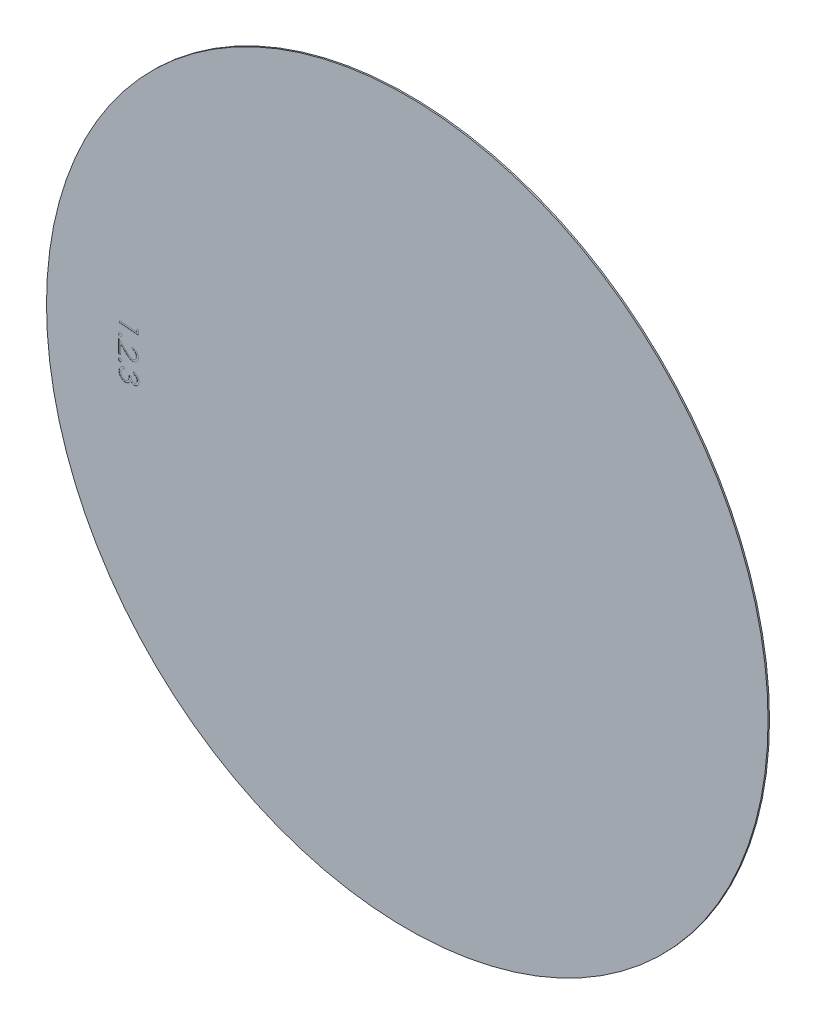
from build123d import *

# Parameters (mm, degrees)
ESQUISSE1_R             = 250
BOSS_EXTRU_1_DEPTH      = 1
ENL_V_MAT_EXTRU_1_DEPTH = 0.1


with BuildPart() as part:
    # Esquisse1 → Boss.-Extru.1 (new body)
    with BuildSketch(Plane.XY):
        Circle(ESQUISSE1_R)
    extrude(amount=BOSS_EXTRU_1_DEPTH)

    # Esquisse2 → Enl_v. mat.-Extru.1 (cut)
    with BuildSketch(Plane.XY.offset(1)):
        Polygon((-186.079389834, 15.769681634), (-186.275495269, 13.183209946), (-199.433109953, 14.171687343), (-199.332407162, 15.478173554), (-187.462728175, 14.585098801), (-187.309023915, 16.652156093), align=None)
        with BuildLine():
            add(Edge.make_bspline(
                [(-197.833748876, 7.192751147), (-197.838665779, 7.118953863), (-197.848276544, 6.974706863), (-197.914579868, 6.767389734), (-198.022946468, 6.580247834), (-198.165854608, 6.414154005), (-198.336130001, 6.275527541), (-198.531123371, 6.179387447), (-198.742825127, 6.120667213), (-198.889852697, 6.116374794), (-198.96533024, 6.114171253)],
                knots=[0, 0, 0, 0, 1.017333611, 1.988519244, 2.970953919, 3.982065248, 4.996402288, 5.977324361, 6.96164652, 8, 8, 8, 8], degree=3))
            add(Edge.make_bspline(
                [(-198.96533024, 6.114171253), (-199.039116519, 6.119100322), (-199.183342007, 6.12873487), (-199.390815461, 6.194865371), (-199.577940796, 6.304237384), (-199.74677394, 6.445156061), (-199.883980713, 6.616885694), (-199.983935465, 6.808389173), (-200.045762135, 7.016691776), (-200.049801761, 7.161405952), (-200.051860355, 7.235152323)],
                knots=[0, 0, 0, 0, 1.021012243, 1.995709639, 2.981696752, 4.005780596, 5.023785433, 6.002922688, 6.982289044, 8, 8, 8, 8], degree=3))
            add(Edge.make_bspline(
                [(-200.051860355, 7.235152323), (-200.0472576, 7.309060654), (-200.038243964, 7.453796324), (-199.967677802, 7.658625516), (-199.862605019, 7.847004622), (-199.716798437, 8.01131819), (-199.543891406, 8.148554803), (-199.350714607, 8.248655534), (-199.14096379, 8.306882188), (-198.996612072, 8.311417307), (-198.922929065, 8.313732217)],
                knots=[0, 0, 0, 0, 1.020640672, 1.998734222, 2.967693326, 3.990089689, 5.017298727, 6.006937189, 6.982659415, 8, 8, 8, 8], degree=3))
            add(Edge.make_bspline(
                [(-198.922929065, 8.313732217), (-198.84817015, 8.309026331), (-198.700928591, 8.299757843), (-198.49237845, 8.230087463), (-198.300819537, 8.125320541), (-198.136974108, 7.978812692), (-197.999836365, 7.809043454), (-197.897656985, 7.619358043), (-197.840795178, 7.410694724), (-197.836130115, 7.266403352), (-197.833748876, 7.192751147)],
                knots=[0, 0, 0, 0, 1.030886514, 2.030384459, 3.008194167, 4.02870078, 5.044454194, 6.010621071, 6.984539818, 8, 8, 8, 8], degree=3))
        make_face()
        with BuildLine():
            Line((-190.780872576, 2.713042324), (-190.780872576, 3.90027523))
            add(Edge.make_bspline(
                [(-190.780872576, 3.90027523), (-190.623365765, 3.892538796), (-190.314026581, 3.877344646), (-189.863021611, 3.806159559), (-189.431881867, 3.704396907), (-189.024303579, 3.560175489), (-188.635417883, 3.38207464), (-188.27038873, 3.164027661), (-187.925593251, 2.910682959), (-187.607559566, 2.622505307), (-187.316837015, 2.309805994), (-187.063126489, 1.974458577), (-186.851218479, 1.619909792), (-186.67310491, 1.249234844), (-186.539571382, 0.858146768), (-186.440448177, 0.450383928), (-186.380820524, 0.024103278), (-186.37441042, -0.266333383), (-186.371150353, -0.414044348)],
                knots=[0, 0, 0, 0, 1.100776268, 2.161895295, 3.184016182, 4.190939212, 5.176500551, 6.166955529, 7.155448256, 8.160289653, 9.16017456, 10.133824356, 11.091467644, 12.04088621, 13.000931625, 13.972173743, 14.968683325, 16, 16, 16, 16], degree=3))
            add(Edge.make_bspline(
                [(-186.371150353, -0.414044348), (-186.374546305, -0.55910433), (-186.381219228, -0.844142014), (-186.438524309, -1.260150223), (-186.528276992, -1.656183449), (-186.654201333, -2.031467567), (-186.823475806, -2.383008347), (-187.026817693, -2.71344664), (-187.261993841, -3.026716371), (-187.538875815, -3.30871225), (-187.834462208, -3.567656478), (-188.150026606, -3.79104893), (-188.475952775, -3.982354638), (-188.814726037, -4.141814023), (-189.169536174, -4.259198834), (-189.535217566, -4.348318846), (-189.915555393, -4.398693297), (-190.172981958, -4.406424511), (-190.303859355, -4.410355112)],
                knots=[0, 0, 0, 0, 1.111607364, 2.184268762, 3.212621178, 4.221274766, 5.211760367, 6.196651075, 7.1921475, 8.207485113, 9.220403448, 10.201281604, 11.166441695, 12.114753415, 13.065576456, 14.026450734, 14.996634279, 16, 16, 16, 16], degree=3))
            add(Edge.make_bspline(
                [(-190.303859355, -4.410355112), (-190.488114563, -4.403954981), (-190.853391561, -4.391267034), (-191.390173929, -4.282733527), (-191.910244293, -4.113224393), (-192.328804929, -3.90912724), (-192.666086289, -3.703234371), (-192.943780501, -3.51769528), (-193.242780337, -3.300491977), (-193.562084558, -3.04846313), (-193.904194229, -2.766822215), (-194.268902682, -2.453018204), (-194.652441812, -2.104813376), (-194.914400484, -1.860419638), (-195.050140905, -1.733780926)],
                knots=[0, 0, 0, 0, 1.184426356, 2.348067706, 3.509069118, 4.696110526, 5.333549288, 6.050745305, 6.844228056, 7.710549037, 8.667450064, 9.695053472, 10.805634456, 12, 12, 12, 12], degree=3))
            Line((-195.050140905, -1.733780926), (-198.582688815, 1.576160814))
            Line((-198.582688815, 1.576160814), (-198.582688815, -4.579959812))
            Line((-198.582688815, -4.579959812), (-199.939526422, -4.579959812))
            Line((-199.939526422, -4.579959812), (-199.939526422, 4.409089333))
            Line((-199.939526422, 4.409089333), (-194.464474672, -0.721452868))
            add(Edge.make_bspline(
                [(-194.464474672, -0.721452868), (-194.3340864, -0.846374855), (-194.083637212, -1.086324427), (-193.717878288, -1.425564838), (-193.378957107, -1.730747386), (-193.065371831, -2.002074512), (-192.778900194, -2.239769466), (-192.517297185, -2.443071728), (-192.282807805, -2.612879857), (-192.007339486, -2.792841089), (-191.670609832, -2.964446065), (-191.261178484, -3.11526928), (-190.838768951, -3.206575603), (-190.55340354, -3.21758459), (-190.409862293, -3.223122206)],
                knots=[0, 0, 0, 0, 1.329530082, 2.553755191, 3.672934919, 4.687409497, 5.60679272, 6.413407421, 7.126401618, 7.737995624, 8.834647426, 9.90044882, 10.943907757, 12, 12, 12, 12], degree=3))
            add(Edge.make_bspline(
                [(-190.409862293, -3.223122206), (-190.319586318, -3.220743934), (-190.141669707, -3.216056818), (-189.880987489, -3.173907196), (-189.628554084, -3.111981036), (-189.387490652, -3.016533694), (-189.15305594, -2.901857227), (-188.932377494, -2.755349583), (-188.717932917, -2.58792982), (-188.517075335, -2.393731106), (-188.333058601, -2.180537002), (-188.170063317, -1.955277612), (-188.033843148, -1.716965139), (-187.922176007, -1.466592737), (-187.834578517, -1.204861489), (-187.773880929, -0.931264349), (-187.735771535, -0.646557512), (-187.730615291, -0.452151143), (-187.72798796, -0.353092658)],
                knots=[0, 0, 0, 0, 0.991504627, 1.954065223, 2.895985987, 3.842598665, 4.797835564, 5.759220273, 6.74786863, 7.784730864, 8.824135544, 9.839918996, 10.835834653, 11.835434876, 12.84861661, 13.863796685, 14.911511676, 16, 16, 16, 16], degree=3))
            add(Edge.make_bspline(
                [(-187.72798796, -0.353092658), (-187.730689795, -0.249636968), (-187.735995751, -0.046467075), (-187.773134679, 0.251821565), (-187.837143711, 0.536407591), (-187.924898737, 0.807867088), (-188.035383012, 1.066461604), (-188.175651116, 1.309852927), (-188.340226467, 1.540263141), (-188.527833384, 1.757269063), (-188.737693955, 1.956663458), (-188.968753699, 2.135536432), (-189.222515633, 2.28809617), (-189.49324804, 2.423333512), (-189.788149357, 2.526810093), (-190.100073448, 2.615260879), (-190.433452007, 2.679513835), (-190.663142285, 2.701680536), (-190.780872576, 2.713042324)],
                knots=[0, 0, 0, 0, 1.031212865, 2.025131798, 2.990757446, 3.934781266, 4.865570067, 5.788494791, 6.729227313, 7.684356718, 8.643577152, 9.610526866, 10.590658432, 11.59095419, 12.621640561, 13.700587263, 14.82141059, 16, 16, 16, 16], degree=3))
        make_face()
        with BuildLine():
            add(Edge.make_bspline(
                [(-197.855890695, -7.952114521), (-197.856231935, -8.025785232), (-197.856903849, -8.170845472), (-197.913200599, -8.380783511), (-198.006935977, -8.576430894), (-198.143394723, -8.748287125), (-198.304408188, -8.898525716), (-198.495167443, -9.004694793), (-198.702469382, -9.077460631), (-198.849055583, -9.090361766), (-198.923870296, -9.096946252)],
                knots=[0, 0, 0, 0, 1.011455231, 1.991591199, 2.966042095, 3.981298704, 4.998232158, 5.979576679, 6.968815689, 8, 8, 8, 8], degree=3))
            add(Edge.make_bspline(
                [(-198.923870296, -9.096946252), (-198.997508424, -9.095459985), (-199.142458049, -9.09253441), (-199.352776447, -9.037452549), (-199.547473772, -8.942039331), (-199.723684047, -8.810838171), (-199.871461627, -8.647745362), (-199.98175034, -8.462057163), (-200.054719908, -8.257510728), (-200.067461559, -8.113494268), (-200.074002174, -8.039566945)],
                knots=[0, 0, 0, 0, 1.016752878, 2.001380979, 2.980297952, 4.002550597, 5.024144834, 6.005578797, 6.976212714, 8, 8, 8, 8], degree=3))
            add(Edge.make_bspline(
                [(-200.074002174, -8.039566945), (-200.072436201, -7.965961841), (-200.069353732, -7.821077221), (-200.015517685, -7.610674016), (-199.916130524, -7.418241398), (-199.781672277, -7.24563965), (-199.619277531, -7.09643759), (-199.432120375, -6.987000911), (-199.226129139, -6.917347401), (-199.082530999, -6.904165351), (-199.008672646, -6.897385288)],
                knots=[0, 0, 0, 0, 1.016913232, 2.00169662, 2.975252904, 3.995323461, 5.017078815, 6.009200989, 6.976051251, 8, 8, 8, 8], degree=3))
            add(Edge.make_bspline(
                [(-199.008672646, -6.897385288), (-198.933243948, -6.897687999), (-198.785579185, -6.898280608), (-198.572794984, -6.954153834), (-198.376389131, -7.04842455), (-198.205173897, -7.18469058), (-198.054984866, -7.343859595), (-197.944945481, -7.529266841), (-197.875936444, -7.734691858), (-197.862699165, -7.878267658), (-197.855890695, -7.952114521)],
                knots=[0, 0, 0, 0, 1.037885945, 2.031841802, 3.008281647, 4.025610493, 5.035601325, 6.014551791, 6.978803386, 8, 8, 8, 8], degree=3))
        make_face()
        with BuildLine():
            Line((-189.439623091, -11.988804985), (-189.542975956, -10.645217745))
            add(Edge.make_bspline(
                [(-189.542975956, -10.645217745), (-189.408296325, -10.667038857), (-189.144125712, -10.709840404), (-188.762207918, -10.807329372), (-188.400617113, -10.921814409), (-188.062889816, -11.063889185), (-187.745483079, -11.225051578), (-187.450084016, -11.411360412), (-187.176881613, -11.620710948), (-186.927088489, -11.851810389), (-186.702901019, -12.101603756), (-186.498943236, -12.363285339), (-186.327294074, -12.643427846), (-186.180335071, -12.935807444), (-186.061720893, -13.242475128), (-185.964915474, -13.560787287), (-185.898149365, -13.894634118), (-185.875957411, -14.122738594), (-185.864674006, -14.238717344)],
                knots=[0, 0, 0, 0, 1.169358419, 2.293666291, 3.376380236, 4.418758499, 5.431657949, 6.425660442, 7.408897509, 8.379064307, 9.339005395, 10.284371877, 11.219762931, 12.151312527, 13.086703581, 14.035674241, 15.001246929, 16, 16, 16, 16], degree=3))
            add(Edge.make_bspline(
                [(-185.864674006, -14.238717344), (-185.856682917, -14.408391366), (-185.840911864, -14.743256614), (-185.895219841, -15.242799697), (-186.005234102, -15.729258501), (-186.179001677, -16.195953942), (-186.397987529, -16.634703956), (-186.668627014, -17.030843658), (-186.982071521, -17.381889388), (-187.341166945, -17.676780771), (-187.725095529, -17.920013067), (-188.127771434, -18.105216632), (-188.543891818, -18.234826088), (-188.830147223, -18.268533449), (-188.973210164, -18.285379504)],
                knots=[0, 0, 0, 0, 1.079062385, 2.129615886, 3.184607817, 4.244094083, 5.289450633, 6.296237251, 7.286901598, 8.272517696, 9.242164218, 10.169895047, 11.085361559, 12, 12, 12, 12], degree=3))
            add(Edge.make_bspline(
                [(-188.973210164, -18.285379504), (-189.112011733, -18.291279474), (-189.384475039, -18.302860939), (-189.786011212, -18.249254941), (-190.170135959, -18.146085207), (-190.53498643, -17.985390623), (-190.881575024, -17.769812623), (-191.207532435, -17.498282401), (-191.521358495, -17.17751131), (-191.702287838, -16.92927749), (-191.795538389, -16.801338371)],
                knots=[0, 0, 0, 0, 0.993539459, 1.950288079, 2.888206921, 3.834604275, 4.795112071, 5.802201012, 6.867259652, 8, 8, 8, 8], degree=3))
            add(Edge.make_bspline(
                [(-191.795538389, -16.801338371), (-191.851865511, -16.959268109), (-191.962539105, -17.269574249), (-192.191553532, -17.703889484), (-192.469199712, -18.099377007), (-192.691645603, -18.329590144), (-192.8025663, -18.444383911)],
                knots=[0, 0, 0, 0, 1.032606511, 2.028903138, 3.017129792, 4, 4, 4, 4], degree=3))
            add(Edge.make_bspline(
                [(-192.8025663, -18.444383911), (-192.884185988, -18.52027061), (-193.044924382, -18.669718698), (-193.308091439, -18.862545711), (-193.578026931, -19.033836872), (-193.859664115, -19.176551879), (-194.150144903, -19.294816688), (-194.451381891, -19.383598617), (-194.761008565, -19.452828444), (-194.972645045, -19.473051739), (-195.078979395, -19.483212704)],
                knots=[0, 0, 0, 0, 1.046552868, 2.061037392, 3.060705633, 4.048305002, 5.024145354, 6.00379209, 6.997027972, 8, 8, 8, 8], degree=3))
            add(Edge.make_bspline(
                [(-195.078979395, -19.483212704), (-195.264630985, -19.490269303), (-195.633834425, -19.504302691), (-196.188049339, -19.430808784), (-196.732492497, -19.283681068), (-197.263100331, -19.066645898), (-197.765408033, -18.786552435), (-198.218893092, -18.439444235), (-198.61833056, -18.033731583), (-198.962542667, -17.574964304), (-199.247387278, -17.068284422), (-199.460290532, -16.519718), (-199.616887046, -15.938700302), (-199.660156733, -15.53553493), (-199.682156979, -15.330547606)],
                knots=[0, 0, 0, 0, 0.967291364, 1.923642562, 2.901252749, 3.901123817, 4.905482908, 5.891197214, 6.868286448, 7.865012392, 8.873387311, 9.888639405, 10.926489748, 12, 12, 12, 12], degree=3))
            add(Edge.make_bspline(
                [(-199.682156979, -15.330547606), (-199.68981465, -15.191889466), (-199.704886479, -14.918982506), (-199.686701635, -14.515857983), (-199.64426042, -14.127058269), (-199.563678417, -13.75462832), (-199.45185972, -13.397186966), (-199.30873098, -13.054400081), (-199.132848161, -12.727033093), (-198.925723242, -12.416056953), (-198.686528457, -12.123617215), (-198.41566643, -11.852941454), (-198.113749436, -11.606053908), (-197.784082303, -11.37907731), (-197.421063072, -11.178261089), (-197.028725666, -10.998305295), (-196.605117582, -10.841030843), (-196.309253065, -10.75713447), (-196.157559289, -10.714119655)],
                knots=[0, 0, 0, 0, 1.04323841, 2.053301916, 3.029289153, 3.979990115, 4.912429175, 5.841006599, 6.767873147, 7.701564391, 8.645283366, 9.603099554, 10.574853829, 11.573084318, 12.607558806, 13.689040711, 14.815139636, 16, 16, 16, 16], degree=3))
            Line((-196.157559289, -10.714119655), (-196.059506571, -12.002055352))
            add(Edge.make_bspline(
                [(-196.059506571, -12.002055352), (-196.160529318, -12.039198272), (-196.356270458, -12.111166199), (-196.63685521, -12.230103298), (-196.892684177, -12.360057958), (-197.127759191, -12.495329377), (-197.340471276, -12.637532003), (-197.528395306, -12.789144656), (-197.696732188, -12.945687958), (-197.791202281, -13.060981975), (-197.837705857, -13.117736275)],
                knots=[0, 0, 0, 0, 1.214465976, 2.353142868, 3.436371674, 4.450190844, 5.412268196, 6.319822283, 7.172920562, 8, 8, 8, 8], degree=3))
            add(Edge.make_bspline(
                [(-197.837705857, -13.117736275), (-197.890579497, -13.190883013), (-197.996077552, -13.336831705), (-198.1250981, -13.574909304), (-198.23253924, -13.823735821), (-198.310000786, -14.086955409), (-198.373414552, -14.358980183), (-198.406081938, -14.645045903), (-198.417718076, -14.942873125), (-198.405675178, -15.145073713), (-198.399521429, -15.248395329)],
                knots=[0, 0, 0, 0, 0.959808397, 1.915092638, 2.875637649, 3.83930699, 4.831632812, 5.845115587, 6.898884799, 8, 8, 8, 8], degree=3))
            add(Edge.make_bspline(
                [(-198.399521429, -15.248395329), (-198.388408768, -15.36441771), (-198.36663526, -15.591745301), (-198.298362086, -15.921155027), (-198.20990129, -16.232349967), (-198.093246542, -16.523210243), (-197.947560447, -16.792458003), (-197.781943674, -17.045865878), (-197.586840786, -17.276757125), (-197.369885115, -17.486070223), (-197.135302748, -17.668718259), (-196.893265336, -17.829660379), (-196.643557558, -17.963240221), (-196.385073031, -18.067573593), (-196.118958146, -18.141014863), (-195.846727174, -18.189943396), (-195.567599043, -18.208588228), (-195.38018879, -18.199739217), (-195.285685124, -18.195277006)],
                knots=[0, 0, 0, 0, 1.167748579, 2.288019524, 3.367064658, 4.408078223, 5.422379026, 6.431913005, 7.437710839, 8.44611765, 9.448908724, 10.414239179, 11.357169125, 12.283059546, 13.202745279, 14.120039995, 15.052009645, 16, 16, 16, 16], degree=3))
            add(Edge.make_bspline(
                [(-195.285685124, -18.195277006), (-195.159555293, -18.180493604), (-194.908612467, -18.151081143), (-194.54426164, -18.039774663), (-194.199874991, -17.871986697), (-193.874535898, -17.65842726), (-193.579544844, -17.399772674), (-193.321476647, -17.104640152), (-193.114918756, -16.770991674), (-192.975379507, -16.468489139), (-192.888068005, -16.202093592), (-192.832978463, -15.976097094), (-192.788970835, -15.725402062), (-192.751862434, -15.451415704), (-192.725754071, -15.152521765), (-192.710285681, -14.829860512), (-192.705679189, -14.482526793), (-192.708405411, -14.243131462), (-192.70981373, -14.119464039)],
                knots=[0, 0, 0, 0, 1.125197128, 2.238646827, 3.360562693, 4.515004594, 5.681571261, 6.831934273, 7.980239031, 9.151851243, 9.778993723, 10.465313815, 11.214101584, 12.036676396, 12.918099741, 13.87557314, 14.902558397, 16, 16, 16, 16], degree=3))
            Line((-192.70981373, -14.119464039), (-191.504030309, -14.026711468))
            add(Edge.make_bspline(
                [(-191.504030309, -14.026711468), (-191.489502808, -14.173821433), (-191.460999231, -14.46245744), (-191.365271694, -14.881029848), (-191.236341344, -15.277375853), (-191.071393777, -15.645494905), (-190.876935536, -15.974882136), (-190.663095219, -16.259275772), (-190.4286651, -16.490644309), (-190.176222282, -16.668534117), (-189.911049214, -16.795916211), (-189.638322572, -16.88301658), (-189.356009092, -16.923505213), (-189.166748245, -16.918045865), (-189.071262882, -16.91529153)],
                knots=[0, 0, 0, 0, 1.265084449, 2.482149492, 3.668921266, 4.830510504, 5.929601171, 6.938982813, 7.869972648, 8.739007758, 9.57146972, 10.380318095, 11.182842527, 12, 12, 12, 12], degree=3))
            add(Edge.make_bspline(
                [(-189.071262882, -16.91529153), (-189.001225418, -16.908038219), (-188.862494327, -16.893670771), (-188.660033591, -16.844505234), (-188.465795827, -16.776404251), (-188.282199923, -16.684250291), (-188.10473948, -16.575737935), (-187.939044535, -16.442424897), (-187.781346837, -16.289725791), (-187.63381875, -16.119340771), (-187.503313147, -15.931931911), (-187.38664058, -15.734856899), (-187.29510306, -15.525295886), (-187.222792357, -15.307103203), (-187.172660547, -15.07876637), (-187.140933721, -14.841274063), (-187.129707012, -14.592859148), (-187.139605982, -14.425075153), (-187.144659483, -14.339420135)],
                knots=[0, 0, 0, 0, 0.942837108, 1.867583633, 2.785101007, 3.69587071, 4.61582951, 5.568135172, 6.539461862, 7.555303943, 8.583491304, 9.596846282, 10.61990788, 11.6420784, 12.673328989, 13.748374332, 14.850527806, 16, 16, 16, 16], degree=3))
            add(Edge.make_bspline(
                [(-187.144659483, -14.339420135), (-187.160429314, -14.202503158), (-187.191285517, -13.934603138), (-187.313645007, -13.554951831), (-187.490651823, -13.207875694), (-187.688942564, -12.950858847), (-187.877067565, -12.763106656), (-188.038142454, -12.627434804), (-188.223694576, -12.503617862), (-188.427028481, -12.384640271), (-188.650874672, -12.27275711), (-188.895975677, -12.170686303), (-189.159418976, -12.071360177), (-189.344710755, -12.01676855), (-189.439623091, -11.988804985)],
                knots=[0, 0, 0, 0, 1.400184103, 2.739684705, 4.034710516, 5.349473374, 6.023481164, 6.738473347, 7.489214871, 8.291200971, 9.135717864, 10.034279935, 10.993095734, 12, 12, 12, 12], degree=3))
        make_face()
    extrude(amount=-ENL_V_MAT_EXTRU_1_DEPTH, mode=Mode.SUBTRACT)


solid = part.part
